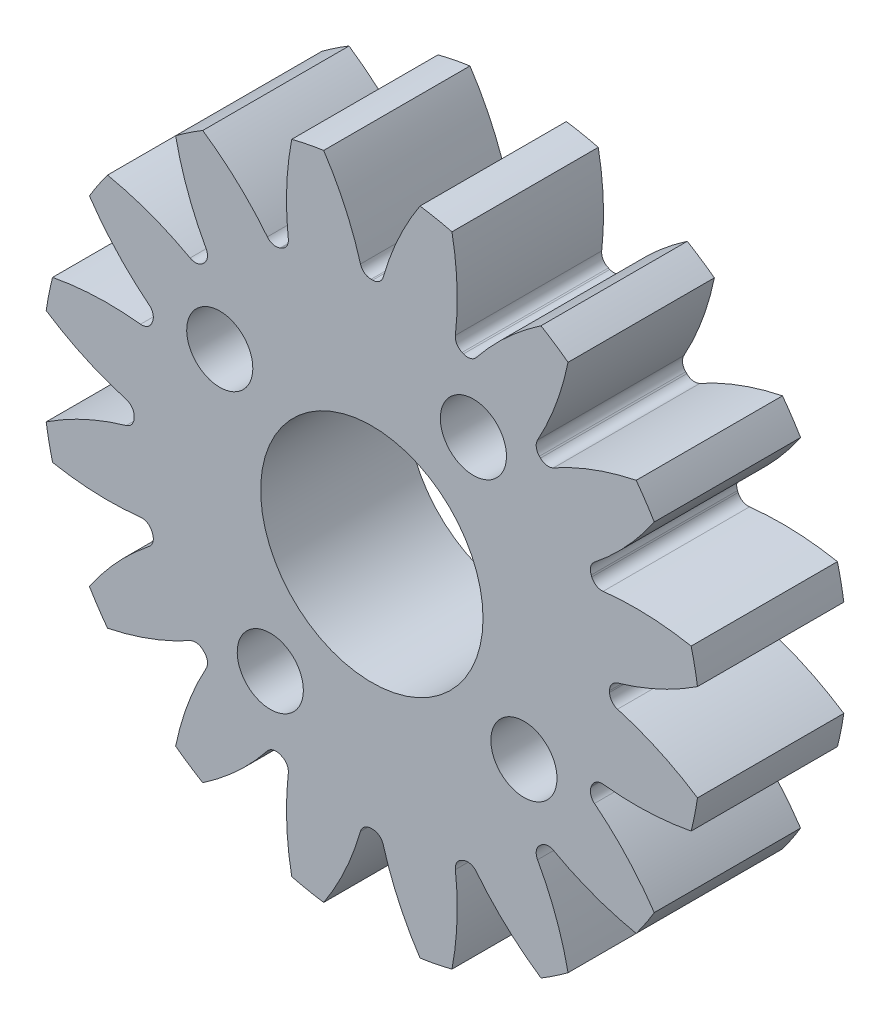
from build123d import *

# Parameters (mm, degrees)
FILLET2_R           = 0.28575
CUT_EXTRUDE2_DEPTH  = 20.05
CIRPATTERN1_COUNT   = 16
SKETCH10_R          = 29.093421686
CUT_EXTRUDE3_DEPTH  = 15.24
SKETCH11_R          = 20.555223038
CUT_EXTRUDE4_DEPTH  = 10.16
SKETCH12_R          = 7.917123479
SKETCH12_R_2        = 4.826
BOSS_EXTRUDE1_DEPTH = 6.35
SKETCH_1_R          = 1.4351
CUT_EXTRUDE_1_DEPTH = 17.51


with BuildPart() as part:
    # Sketch4 → Revolve1 (revolve)
    with BuildSketch(Plane(origin=(0, 0, 0), x_dir=(0, 0, -1), z_dir=(1, 0, 0))):
        Polygon((-31.75, 6.35), (-31.75, 10.3251), (-19.05, 10.3251), (-19.05, 14.2875), (0, 14.2875), (0, 6.35), align=None)
    revolve(axis=Axis((0, 0, 19.05), (0, 0, 1)))

    # Fillet2
    fillet2_edges = [part.edges().sort_by_distance(p)[0] for p in [
        (0, -14.2875, 0),
        (0, -14.2875, 19.05),
        (0, -10.3251, 19.05),
        (0, -10.3251, 31.75),
    ]]
    fillet(fillet2_edges, radius=FILLET2_R)

    # Sketch7 → Cut-Extrude2 (cut, through all)
    with BuildSketch(Plane.XY.offset(19.05)):
        with BuildLine():
            ThreePointArc((-0.033120764, 10.318696845), (0, 10.31875), (0.033120764, 10.318696845))
            ThreePointArc((0.033120764, 10.318696845), (0.320422165, 10.413952701), (0.492309784, 10.663092059))
            ThreePointArc((0.492309784, 10.663092059), (1.160210792, 12.458856869), (2.090652449, 14.133712484))
            ThreePointArc((2.090652449, 14.133712484), (0, 14.2875), (-2.090652449, 14.133712484))
            ThreePointArc((-2.090652449, 14.133712484), (-1.160210792, 12.458856869), (-0.492309784, 10.663092059))
            ThreePointArc((-0.492309784, 10.663092059), (-0.320422165, 10.413952701), (-0.033120764, 10.318696845))
        make_face()
    cut_extrude2 = extrude(amount=-CUT_EXTRUDE2_DEPTH, mode=Mode.SUBTRACT)

    # CirPattern1: Cut-Extrude2 ×16 about axis
    cirpattern1_axis = Axis((0, 0, 0), (0, 0, 1))
    for i in range(1, CIRPATTERN1_COUNT):
        add(cut_extrude2.rotate(cirpattern1_axis, i * 360 / CIRPATTERN1_COUNT), mode=Mode.SUBTRACT)

    # Sketch10 → Cut-Extrude3 (cut)
    with BuildSketch(Plane.XY.offset(31.75)):
        Circle(SKETCH10_R)
    extrude(amount=-CUT_EXTRUDE3_DEPTH, mode=Mode.SUBTRACT)

    # Sketch11 → Cut-Extrude4 (cut)
    with BuildSketch(Plane(origin=(0, 0, 0), x_dir=(-1, 0, 0), z_dir=(0, 0, -1))):
        Circle(SKETCH11_R)
    extrude(amount=-CUT_EXTRUDE4_DEPTH, mode=Mode.SUBTRACT)

    # Sketch12 → Boss-Extrude1 (add)
    with BuildSketch(Plane.XY.offset(16.51)):
        Circle(SKETCH12_R)
        Circle(SKETCH12_R_2, mode=Mode.SUBTRACT)
    extrude(amount=-BOSS_EXTRUDE1_DEPTH)

    # Эскиз1 → Вырез-Вытянуть1 (cut, through all)
    with BuildSketch(Plane(origin=(0, 0, 0), x_dir=(-1, 0, 0), z_dir=(0, 0, -1))):
        with Locations((6.601034981, 4.40797498)):
            Circle(SKETCH_1_R)
        with Locations((4.40797498, -6.601034981)):
            Circle(SKETCH_1_R)
        with Locations((-6.601034981, -4.40797498)):
            Circle(SKETCH_1_R)
        with Locations((-4.40797498, 6.601034981)):
            Circle(SKETCH_1_R)
    extrude(amount=-CUT_EXTRUDE_1_DEPTH, mode=Mode.SUBTRACT)


solid = part.part
